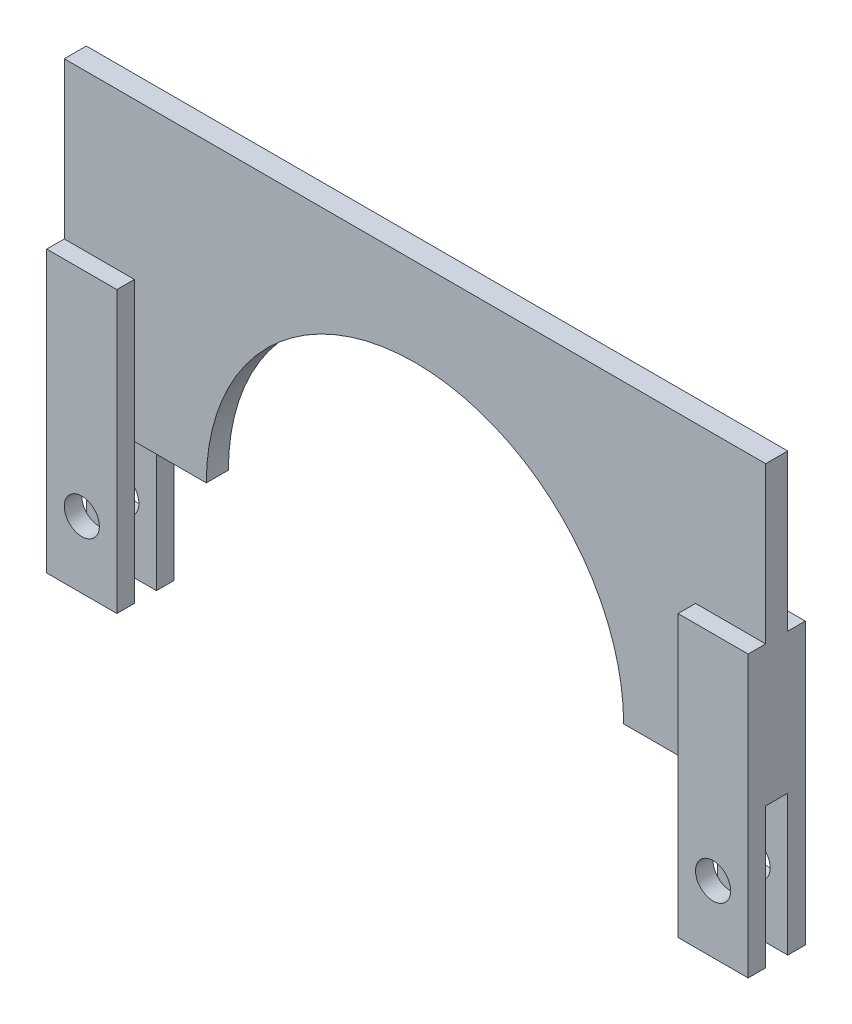
from build123d import *

# Parameters (mm, degrees)
BOSS_EXTRUDE1_DEPTH     = 0.798558565
SKETCH2_W               = 5.08
SKETCH2_H               = 10.16
BOSS_EXTRUDE3_DEPTH     = 1.27
MIRROR2_COPY_1_SKETCH_W = 5.08
MIRROR2_COPY_1_SKETCH_H = 10.16
MIRROR2_COPY_1_DEPTH    = 1.27
SKETCH3_R               = 1.27
CUT_EXTRUDE1_DEPTH      = 5.13711713


with BuildPart() as part:
    # Sketch1 → Boss-Extrude1 (new body, symmetric)
    with BuildSketch(Plane.XY):
        with BuildLine():
            Line((-25.4, 0), (-15.113, 0))
            ThreePointArc((-15.113, 0), (0, 15.113), (15.113, 0))
            Line((15.113, 0), (25.4, 0))
            Line((25.4, 0), (25.4, 21.463))
            Line((25.4, 21.463), (-25.4, 21.463))
            Line((-25.4, 21.463), (-25.4, 0))
        make_face()
    extrude(amount=BOSS_EXTRUDE1_DEPTH, both=True)

    # Sketch2 → Boss-Extrude3 (add)
    with BuildSketch(Plane.XY.offset(0.798558565)):
        with Locations((22.86, 5.08)):
            Rectangle(SKETCH2_W, SKETCH2_H)
        with Locations((22.86, -5.08)):
            Rectangle(SKETCH2_W, SKETCH2_H)
    boss_extrude3 = extrude(amount=BOSS_EXTRUDE3_DEPTH)

    # Mirror1: Boss-Extrude3 across plane
    add(boss_extrude3.mirror(Plane.XY))

    # Mirror2: Boss-Extrude3 across plane
    add(boss_extrude3.mirror(Plane(origin=(0, 0, 0), x_dir=(0, 0, 1), z_dir=(1, 0, 0))))

    # Mirror2 copy 1 sketch → Mirror2 copy 1 (add)
    with BuildSketch(Plane(origin=(0, 0, -0.798558565), x_dir=(-1, 0, 0), z_dir=(0, 0, -1))):
        with Locations((22.86, 5.08)):
            Rectangle(MIRROR2_COPY_1_SKETCH_W, MIRROR2_COPY_1_SKETCH_H)
        with Locations((22.86, -5.08)):
            Rectangle(MIRROR2_COPY_1_SKETCH_W, MIRROR2_COPY_1_SKETCH_H)
    extrude(amount=MIRROR2_COPY_1_DEPTH)

    # Sketch3 → Cut-Extrude1 (cut, through all)
    with BuildSketch(Plane(origin=(0, 0, -2.068558565), x_dir=(-1, 0, 0), z_dir=(0, 0, -1))):
        with Locations((-22.86, -5.334)):
            Circle(SKETCH3_R)
    cut_extrude1 = extrude(amount=-CUT_EXTRUDE1_DEPTH, mode=Mode.SUBTRACT)

    # Mirror3: Cut-Extrude1 across plane
    add(cut_extrude1.mirror(Plane(origin=(0, 0, 0), x_dir=(0, 0, 1), z_dir=(1, 0, 0))), mode=Mode.SUBTRACT)


solid = part.part
